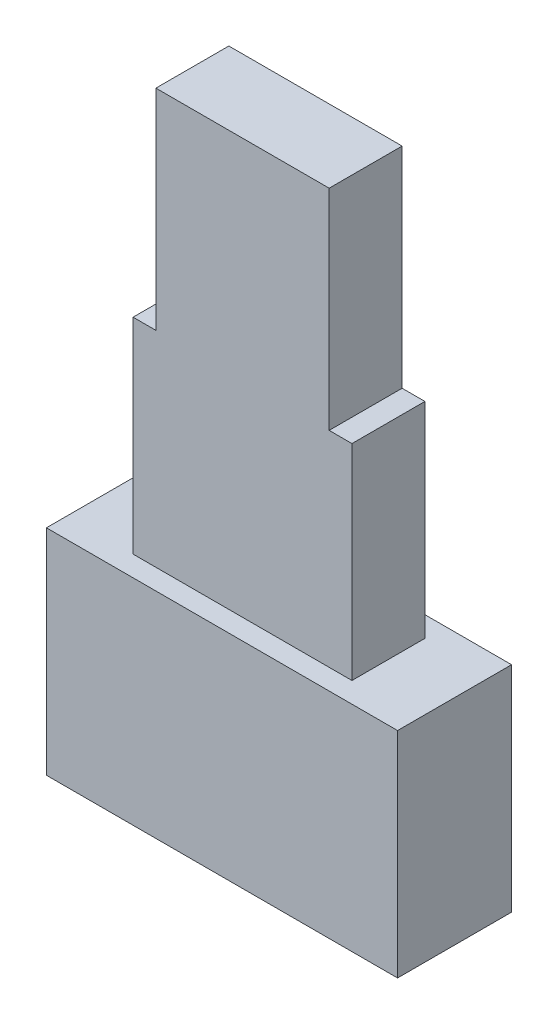
from build123d import *

# Parameters (mm, degrees)
SKETCH1_W           = 7.7
SKETCH1_H           = 2.5
BOSS_EXTRUDE1_DEPTH = 4.7
SKETCH2_W           = 4.8
SKETCH2_H           = 1.6
BOSS_EXTRUDE2_DEPTH = 4.5
SKETCH3_W           = 3.8
SKETCH3_H           = 1.6
BOSS_EXTRUDE3_DEPTH = 4.6


with BuildPart() as part:
    # Sketch1 → Boss-Extrude1 (new body)
    with BuildSketch(Plane(origin=(0, 0, 0), x_dir=(1, 0, 0), z_dir=(0, 1, 0))):
        Rectangle(SKETCH1_W, SKETCH1_H)
    extrude(amount=BOSS_EXTRUDE1_DEPTH)

    # Sketch2 → Boss-Extrude2 (add)
    with BuildSketch(Plane(origin=(0, 4.7, 0), x_dir=(1, 0, 0), z_dir=(0, 1, 0))):
        Rectangle(SKETCH2_W, SKETCH2_H)
    extrude(amount=BOSS_EXTRUDE2_DEPTH)

    # Sketch3 → Boss-Extrude3 (add)
    with BuildSketch(Plane(origin=(0, 9.2, 0), x_dir=(1, 0, 0), z_dir=(0, 1, 0))):
        Rectangle(SKETCH3_W, SKETCH3_H)
    extrude(amount=BOSS_EXTRUDE3_DEPTH)


solid = part.part
